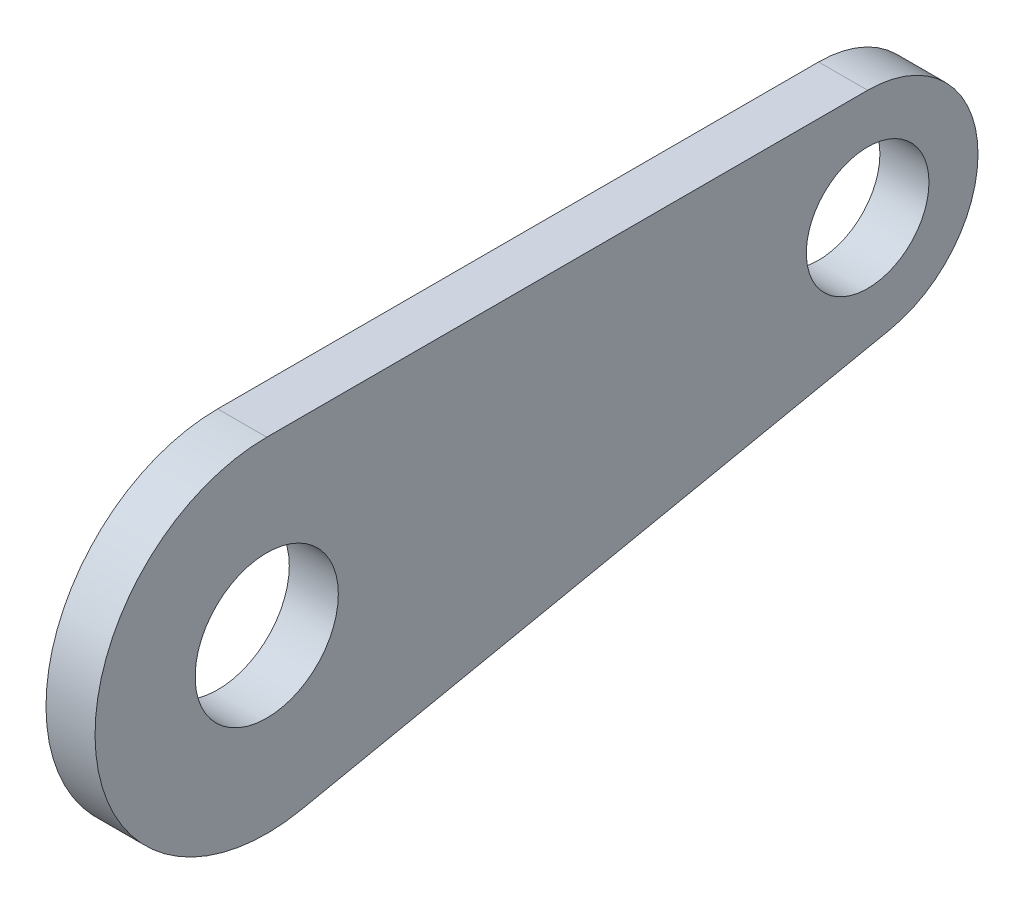
from build123d import *

# Parameters (mm, degrees)
SKETCH1_R           = 2.35458
SKETCH1_R_2         = 2.01676
BOSS_EXTRUDE1_DEPTH = 1.6129


with BuildPart() as part:
    # Sketch1 → Boss-Extrude1 (new body)
    with BuildSketch(Plane(origin=(0, 0, 0), x_dir=(0, 0, -1), z_dir=(1, 0, 0))):
        with BuildLine():
            Line((-14.445578284, 5.64642), (5.315621716, 5.64642))
            ThreePointArc((5.315621716, 5.64642), (8.926525669, 2.385276419), (6.048845981, -1.538069657))
            Line((6.048845981, -1.538069657), (-13.304950193, -5.530011426))
            ThreePointArc((-13.304950193, -5.530011426), (-20.062820754, -0.573276417), (-14.445578284, 5.64642))
        make_face()
        with Locations((-14.445578284, 0)):
            Circle(SKETCH1_R, mode=Mode.SUBTRACT)
        with Locations((5.315621716, 2.01676)):
            Circle(SKETCH1_R_2, mode=Mode.SUBTRACT)
    extrude(amount=-BOSS_EXTRUDE1_DEPTH)


solid = part.part
